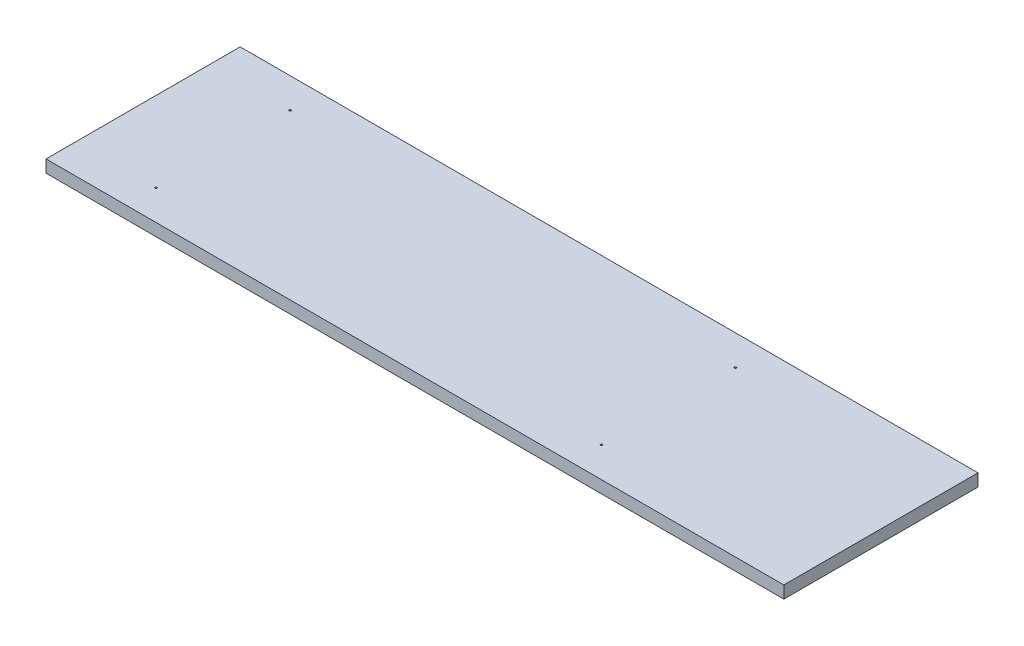
from build123d import *

# Parameters (mm, degrees)
SKETCH1_W           = 760
SKETCH1_H           = 200
BOSS_EXTRUDE1_DEPTH = 12.7
SKETCH2_R           = 1
CUT_EXTRUDE1_DEPTH  = 8


with BuildPart() as part:
    # Sketch1 → Boss-Extrude1 (new body)
    with BuildSketch(Plane(origin=(0, 0, 0), x_dir=(1, 0, 0), z_dir=(0, 1, 0))):
        with Locations((380, 100)):
            Rectangle(SKETCH1_W, SKETCH1_H)
    extrude(amount=-BOSS_EXTRUDE1_DEPTH)

    # Sketch2 → Cut-Extrude1 (cut)
    with BuildSketch(Plane(origin=(0, 0, 0), x_dir=(1, 0, 0), z_dir=(0, 1, 0))):
        with Locations(Location((82.4, 31, 0), (0, 0, 270))):  # turned: the seam where the file's is
            Circle(SKETCH2_R)
        with Locations(Location((82.4, 169, 0), (0, 0, 270))):  # turned: the seam where the file's is
            Circle(SKETCH2_R)
        with Locations(Location((541.2, 31, 0), (0, 0, 270))):  # turned: the seam where the file's is
            Circle(SKETCH2_R)
        with Locations(Location((541.2, 169, 0), (0, 0, 270))):  # turned: the seam where the file's is
            Circle(SKETCH2_R)
    extrude(amount=-CUT_EXTRUDE1_DEPTH, mode=Mode.SUBTRACT)


solid = part.part
